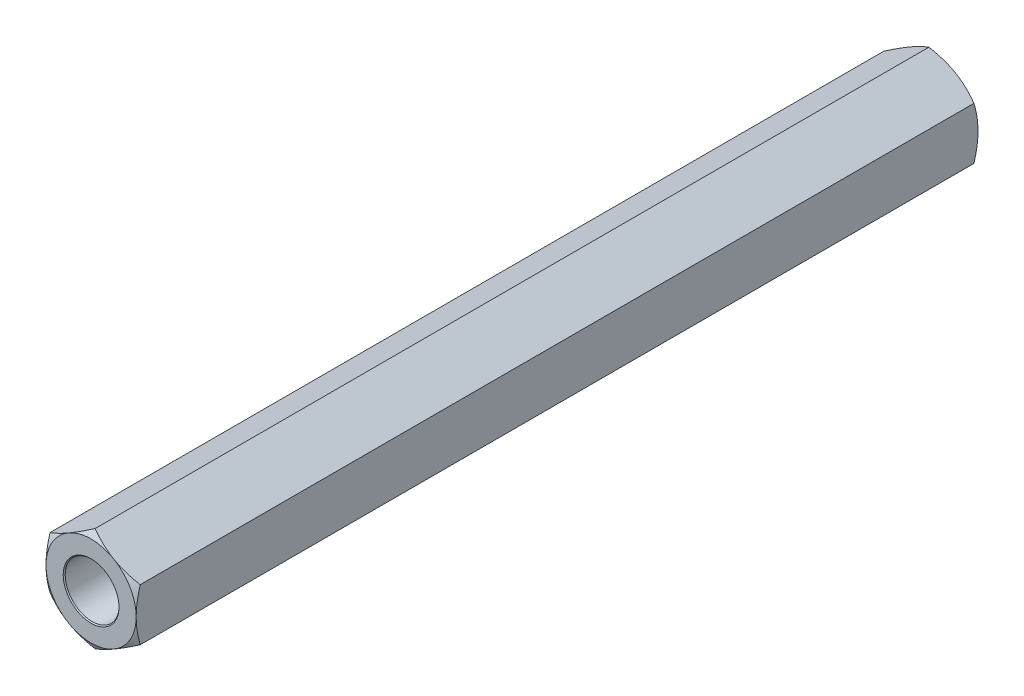
from build123d import *

# Parameters (mm, degrees)
EXTRUDE1_DEPTH          = 22.225
EXTRUDE1_DEPTH_BACK     = 22.225
SKETCH1_R               = 1.4224
SKETCH8_OUTSIDE_W       = 173.728
SKETCH8_OUTSIDE_H       = 174.466
SKETCH8_OUTSIDE_R       = 2.38125
EXTRUDE4_DEPTH          = 45.598579802
EXTRUDE4_DRAFT          = -60
MIRROR1_COPY_1_SKETCH_W = 173.728
MIRROR1_COPY_1_SKETCH_H = 174.466
MIRROR1_COPY_1_SKETCH_R = 2.38125
MIRROR1_COPY_1_DEPTH    = 45.598579802
MIRROR1_COPY_1_DRAFT    = -60


with BuildPart() as part:
    # Sketch1 → Extrude1 (new, two sides: drawn at the far end of the back side and taken through both)
    with BuildSketch(Plane.XY.offset(-EXTRUDE1_DEPTH_BACK)):
        Polygon((0, 2.749630657), (-2.38125, 1.374815329), (-2.38125, -1.374815329), (0, -2.749630657), (2.38125, -1.374815329), (2.38125, 1.374815329), align=None)
        Circle(SKETCH1_R, mode=Mode.SUBTRACT)
    extrude(amount=EXTRUDE1_DEPTH + EXTRUDE1_DEPTH_BACK)

    # Extrude3 cone 1 section (through the dimple's axis) → Extrude3 (revolve, cut)
    with BuildSketch(Plane(origin=(0, 0, -22.225), x_dir=(0, 1, 0), z_dir=(1, 0, 0))):
        Polygon((0, 0), (1.4732, 0), (0, 1.579813584), align=None)
    extrude3 = revolve(axis=Axis((0, 0, -22.225), (0, 0, 1)), mode=Mode.SUBTRACT)


with BuildPart() as extrude4_tool:
    # Sketch8 outside → Extrude4 (with draft: the straight prism first)
    with BuildSketch(Plane(origin=(0, 0, -22.225), x_dir=(-1, 0, 0), z_dir=(0, 0, -1))):
        Rectangle(SKETCH8_OUTSIDE_W, SKETCH8_OUTSIDE_H)
        Circle(SKETCH8_OUTSIDE_R, mode=Mode.SUBTRACT)
    extrude(amount=-EXTRUDE4_DEPTH)
    # Extrude4: the draft: its side faces are tilted about the plane it starts from
    extrude4_sides = [extrude4_tool.faces().sort_by_distance(p)[0] for p in [
        (0, -87.233, 0.574289901),
        (-86.864, 0, 0.574289901),
        (0, 87.233, 0.574289901),
        (86.864, 0, 0.574289901),
        (2.38125, 0, 0.574289901),
    ]]
    draft(extrude4_sides, Plane(origin=(0, 0, -22.225), x_dir=(-1, 0, 0), z_dir=(0, 0, -1)), EXTRUDE4_DRAFT)


with BuildPart() as part_1:
    add(part.part)

    # Extrude4: cut by extrude4_tool
    add(extrude4_tool.part, mode=Mode.SUBTRACT)

    # Mirror1: Extrude3 across plane
    add(extrude3.mirror(Plane.XY), mode=Mode.SUBTRACT)


with BuildPart() as mirror1_copy_1_tool:
    # Mirror1 copy 1 sketch → Mirror1 copy 1 (with draft: the straight prism first)
    with BuildSketch(Plane(origin=(0, 0, 22.225), x_dir=(-1, 0, 0), z_dir=(0, 0, 1))):
        Rectangle(MIRROR1_COPY_1_SKETCH_W, MIRROR1_COPY_1_SKETCH_H)
        Circle(MIRROR1_COPY_1_SKETCH_R, mode=Mode.SUBTRACT)
    extrude(amount=-MIRROR1_COPY_1_DEPTH)
    # Mirror1 copy 1: the draft: its side faces are tilted about the plane it starts from
    mirror1_copy_1_sides = [mirror1_copy_1_tool.faces().sort_by_distance(p)[0] for p in [
        (0, -87.233, -0.574289901),
        (-86.864, 0, -0.574289901),
        (0, 87.233, -0.574289901),
        (86.864, 0, -0.574289901),
        (2.38125, 0, -0.574289901),
    ]]
    draft(mirror1_copy_1_sides, Plane(origin=(0, 0, 22.225), x_dir=(-1, 0, 0), z_dir=(0, 0, 1)), MIRROR1_COPY_1_DRAFT)


with BuildPart() as part_2:
    add(part_1.part)

    # Mirror1 copy 1: cut by mirror1_copy_1_tool
    add(mirror1_copy_1_tool.part, mode=Mode.SUBTRACT)


solid = part_2.part
